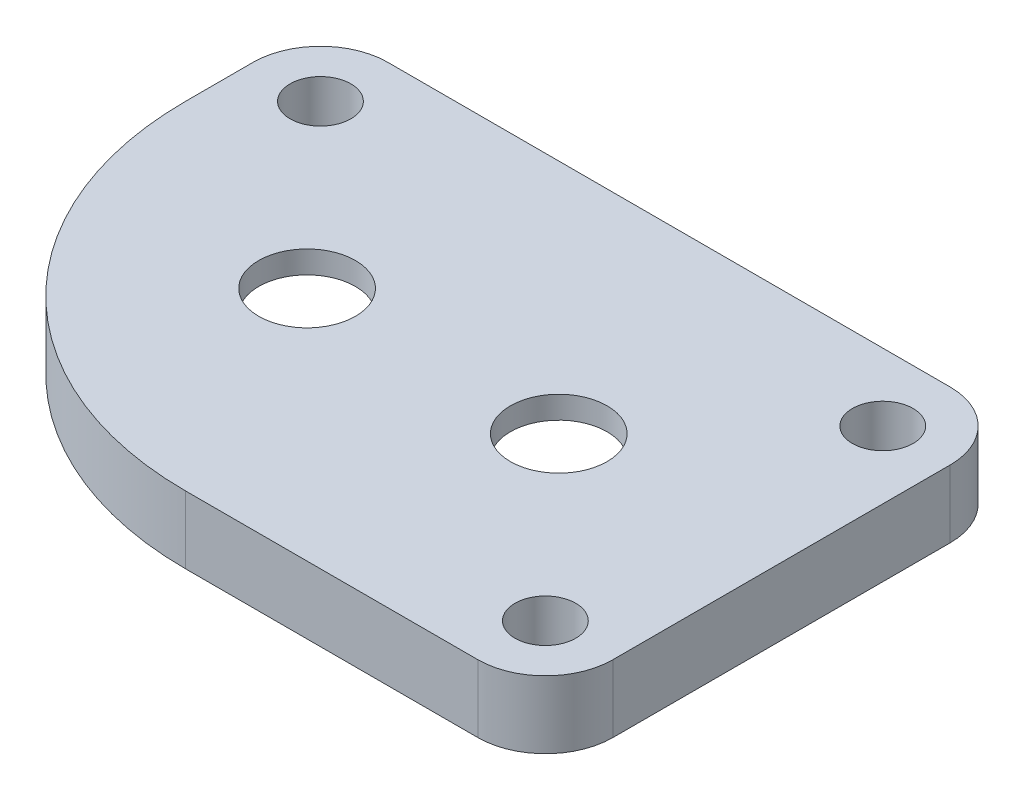
from build123d import *

# Parameters (mm, degrees)
SKETCH1_R           = 2.15
SKETCH1_R_2         = 1.35
BOSS_EXTRUDE1_DEPTH = 3
CUT_EXTRUDE1_DEPTH  = 2


with BuildPart() as part:
    # Sketch1 → Boss-Extrude1 (new body)
    with BuildSketch(Plane(origin=(0, 0, 0), x_dir=(1, 0, 0), z_dir=(0, 1, 0))):
        with BuildLine():
            Line((5.095, -10.5), (18.095, -10.5))
            ThreePointArc((18.095, -10.5), (20.216320344, -9.621320344), (21.095, -7.5))
            Line((21.095, -7.5), (21.095, 7.5))
            ThreePointArc((21.095, 7.5), (20.216320344, 9.621320344), (18.095, 10.5))
            Line((18.095, 10.5), (-6.905, 10.5))
            ThreePointArc((-6.905, 10.5), (-9.026320344, 9.621320344), (-9.905, 7.5))
            Line((-9.905, 7.5), (-9.905, 4.5))
            ThreePointArc((-9.905, 4.5), (-5.511601718, -6.106601718), (5.095, -10.5))
        make_face()
        Circle(SKETCH1_R, mode=Mode.SUBTRACT)
        with Locations((11.19, 0)):
            Circle(SKETCH1_R, mode=Mode.SUBTRACT)
        with Locations((-6.905, 7.5)):
            Circle(SKETCH1_R_2, mode=Mode.SUBTRACT)
        with Locations((18.095, 7.5)):
            Circle(SKETCH1_R_2, mode=Mode.SUBTRACT)
        with Locations((18.095, -7.5)):
            Circle(SKETCH1_R_2, mode=Mode.SUBTRACT)
    extrude(amount=BOSS_EXTRUDE1_DEPTH)

    # Sketch2 → Cut-Extrude1 (cut)
    with BuildSketch(Plane.XZ):
        with BuildLine():
            Line((0, 6.29609527), (11.19, 6.29609527))
            ThreePointArc((11.19, 6.29609527), (17.48609527, 0), (11.19, -6.29609527))
            Line((11.19, -6.29609527), (0, -6.29609527))
            ThreePointArc((0, -6.29609527), (-6.29609527, 0), (0, 6.29609527))
        make_face()
    extrude(amount=-CUT_EXTRUDE1_DEPTH, mode=Mode.SUBTRACT)


solid = part.part
